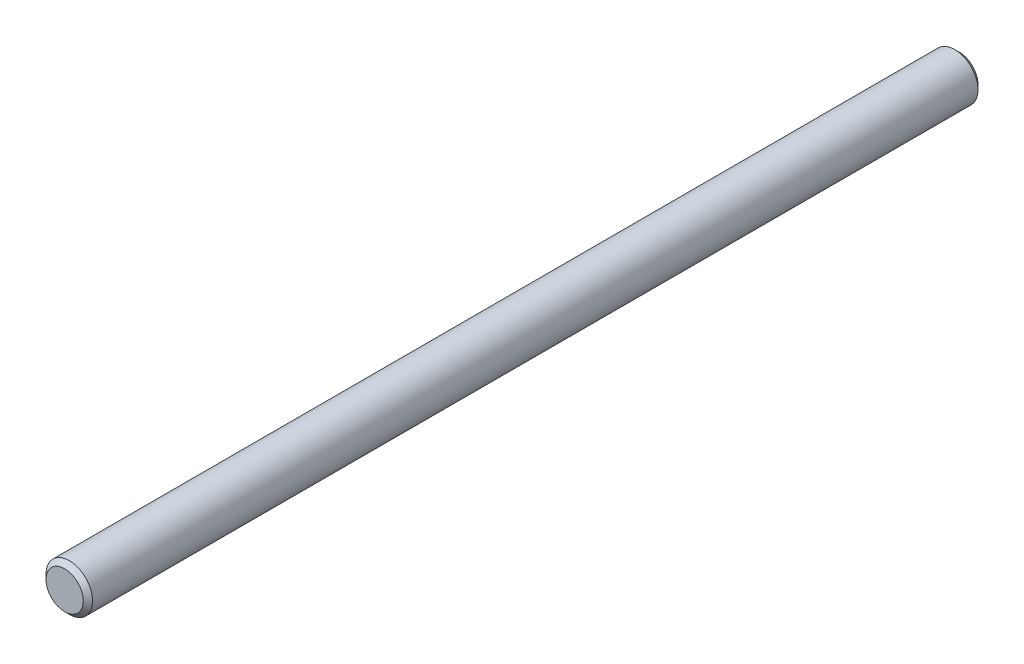
from build123d import *

# Parameters (mm, degrees)
SKETCH3_R           = 3.96875
BOSS_EXTRUDE1_DEPTH = 76.2
CHAMFER1_SIZE       = 0.79375


with BuildPart() as part:
    # Sketch3 → Boss-Extrude1 (new body, symmetric)
    with BuildSketch(Plane.XY):
        Circle(SKETCH3_R)
    extrude(amount=BOSS_EXTRUDE1_DEPTH, both=True)

    # Chamfer1
    chamfer1_edges = [part.edges().sort_by_distance(p)[0] for p in [
        (-3.96875, 0, -76.2),
        (-3.96875, 0, 76.2),
    ]]
    chamfer(chamfer1_edges, length=CHAMFER1_SIZE)


solid = part.part
